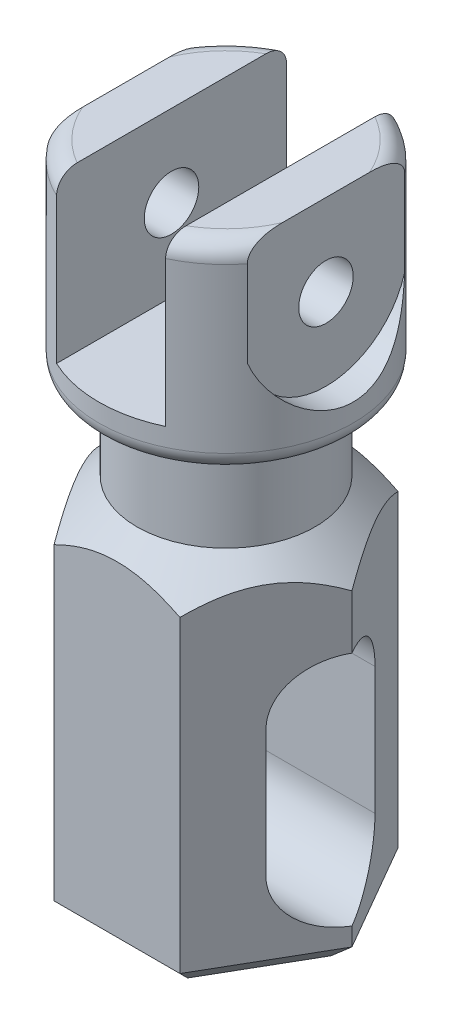
from build123d import *

# Parameters (mm, degrees)
BOSS_EXTRUDE1_DEPTH     = 100
CHAMFER1_SIZE           = 5
CUT_EXTRUDE1_DEPTH      = 35.641016151
CUT_EXTRUDE1_DEPTH_BACK = 35.641016151
SKETCH3_R               = 24.5
BOSS_EXTRUDE2_DEPTH     = 25
SKETCH5_R               = 35
BOSS_EXTRUDE3_DEPTH     = 55
FILLET1_R               = 5
SKETCH6_W               = 30
SKETCH6_H               = 45
CUT_EXTRUDE2_DEPTH      = 36.0000001
CUT_EXTRUDE2_DEPTH_BACK = 36.0000001
CUT_EXTRUDE3_DEPTH      = 8.5
SKETCH8_R               = 7.5
CUT_EXTRUDE4_DEPTH      = 55
FILLET2_R               = 5
SKETCH9_R               = 7.5
CUT_EXTRUDE5_DEPTH      = 181.0000001


with BuildPart() as part:
    # Sketch1 → Boss-Extrude1 (new body)
    with BuildSketch(Plane(origin=(0, 0, 0), x_dir=(1, 0, 0), z_dir=(0, 1, 0))):
        Polygon((34.641016151, 0), (17.320508076, 30), (-17.320508076, 30), (-34.641016151, 0), (-17.320508076, -30), (17.320508076, -30), align=None)
    extrude(amount=BOSS_EXTRUDE1_DEPTH)

    # Chamfer1
    chamfer1_edges = [part.edges().sort_by_distance(p)[0] for p in [
        (0, 0, 30),
        (-25.980762114, 0, 15),
        (-25.980762114, 0, -15),
        (0, 0, -30),
        (25.980762114, 0, -15),
        (25.980762114, 0, 15),
    ]]
    chamfer(chamfer1_edges, length=CHAMFER1_SIZE)

    # Sketch2 → Cut-Extrude1 (cut, two sides)
    with BuildSketch(Plane(origin=(0, 0, 0), x_dir=(0, 0, -1), z_dir=(1, 0, 0))) as cut_extrude1_sk:
        with BuildLine():
            Line((15, 60), (15, 25))
            ThreePointArc((15, 25), (0, 10), (-15, 25))
            Line((-15, 25), (-15, 60))
            ThreePointArc((-15, 60), (0, 75), (15, 60))
        make_face()
    extrude(amount=CUT_EXTRUDE1_DEPTH, mode=Mode.SUBTRACT)
    extrude(cut_extrude1_sk.sketch, amount=-CUT_EXTRUDE1_DEPTH_BACK, mode=Mode.SUBTRACT)

    # Sketch3 → Boss-Extrude2 (add)
    with BuildSketch(Plane(origin=(0, 100, 0), x_dir=(1, 0, 0), z_dir=(0, 1, 0))):
        Circle(SKETCH3_R)
    extrude(amount=BOSS_EXTRUDE2_DEPTH)

    # Sketch4 → Cut-Revolve1 (revolve, cut)
    with BuildSketch(Plane.XY):
        Polygon((-24.5, 100), (-37.5, 87), (-37.5, 100), align=None)
    revolve(axis=Axis((0, -6.25, 0), (0, 1, 0)), mode=Mode.SUBTRACT)

    # Sketch5 → Boss-Extrude3 (add)
    with BuildSketch(Plane(origin=(0, 125, 0), x_dir=(1, 0, 0), z_dir=(0, 1, 0))):
        Circle(SKETCH5_R)
    extrude(amount=BOSS_EXTRUDE3_DEPTH)

    # Fillet1
    fillet1_edges = [part.edges().sort_by_distance(p)[0] for p in [
        (-35, 125, 0),
    ]]
    fillet(fillet1_edges, radius=FILLET1_R)

    # Sketch6 → Cut-Extrude2 (cut, two sides)
    with BuildSketch(Plane.XY) as cut_extrude2_sk:
        with Locations((0, 157.5)):
            Rectangle(SKETCH6_W, SKETCH6_H)
    extrude(amount=CUT_EXTRUDE2_DEPTH, mode=Mode.SUBTRACT)
    extrude(cut_extrude2_sk.sketch, amount=-CUT_EXTRUDE2_DEPTH_BACK, mode=Mode.SUBTRACT)

    # Sketch7 → Cut-Extrude3 (cut, through all)
    with BuildSketch(Plane(origin=(27.5, 0, 0), x_dir=(0, 0, -1), z_dir=(1, 0, 0))):
        with BuildLine():
            Line((-22.5, 180), (22.5, 180))
            Line((22.5, 180), (22.5, 157.5))
            ThreePointArc((22.5, 157.5), (0, 135), (-22.5, 157.5))
            Line((-22.5, 157.5), (-22.5, 180))
        make_face()
    cut_extrude3 = extrude(amount=CUT_EXTRUDE3_DEPTH, mode=Mode.SUBTRACT)

    # Mirror1: Cut-Extrude3 across plane
    add(cut_extrude3.mirror(Plane(origin=(0, 0, 0), x_dir=(0, 0, 1), z_dir=(1, 0, 0))), mode=Mode.SUBTRACT)

    # Sketch8 → Cut-Extrude4 (cut)
    with BuildSketch(Plane(origin=(27.5, 0, 0), x_dir=(0, 0, -1), z_dir=(1, 0, 0))):
        with Locations((0, 157.5)):
            Circle(SKETCH8_R)
    extrude(amount=-CUT_EXTRUDE4_DEPTH, mode=Mode.SUBTRACT)

    # Fillet2
    fillet2_edges = [part.edges().sort_by_distance(p)[0] for p in [
        (21.827125362, 180, -27.360127895),
        (-21.827125362, 180, 27.360127895),
        (21.827125362, 180, 27.360127895),
        (-21.827125362, 180, -27.360127895),
    ]]
    fillet(fillet2_edges, radius=FILLET2_R)

    # Sketch9 → Cut-Extrude5 (cut, through all)
    with BuildSketch(Plane.XZ):
        Circle(SKETCH9_R)
    extrude(amount=-CUT_EXTRUDE5_DEPTH, mode=Mode.SUBTRACT)


solid = part.part
